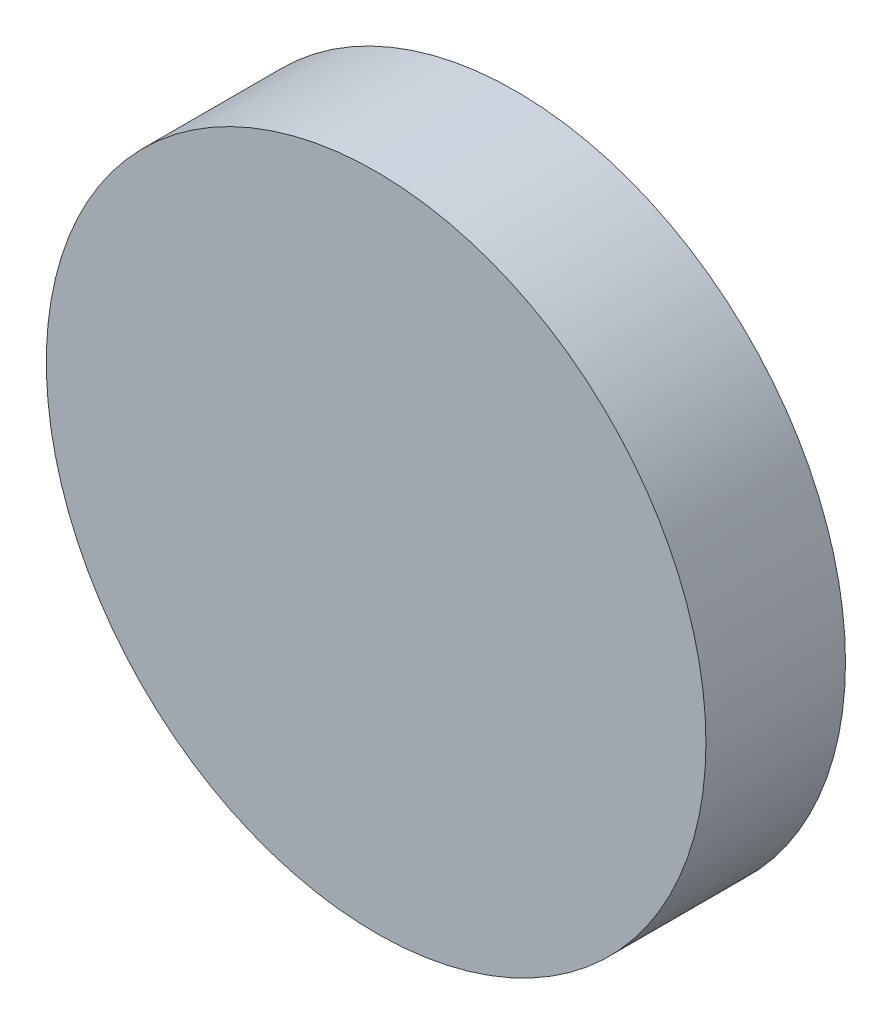
from build123d import *

# Parameters (mm, degrees)
SKETCH1_R           = 26
BOSS_EXTRUDE1_DEPTH = 11


with BuildPart() as part:
    # Sketch1 → Boss-Extrude1 (new body)
    with BuildSketch(Plane.XY):
        Circle(SKETCH1_R)
    extrude(amount=BOSS_EXTRUDE1_DEPTH)


solid = part.part
